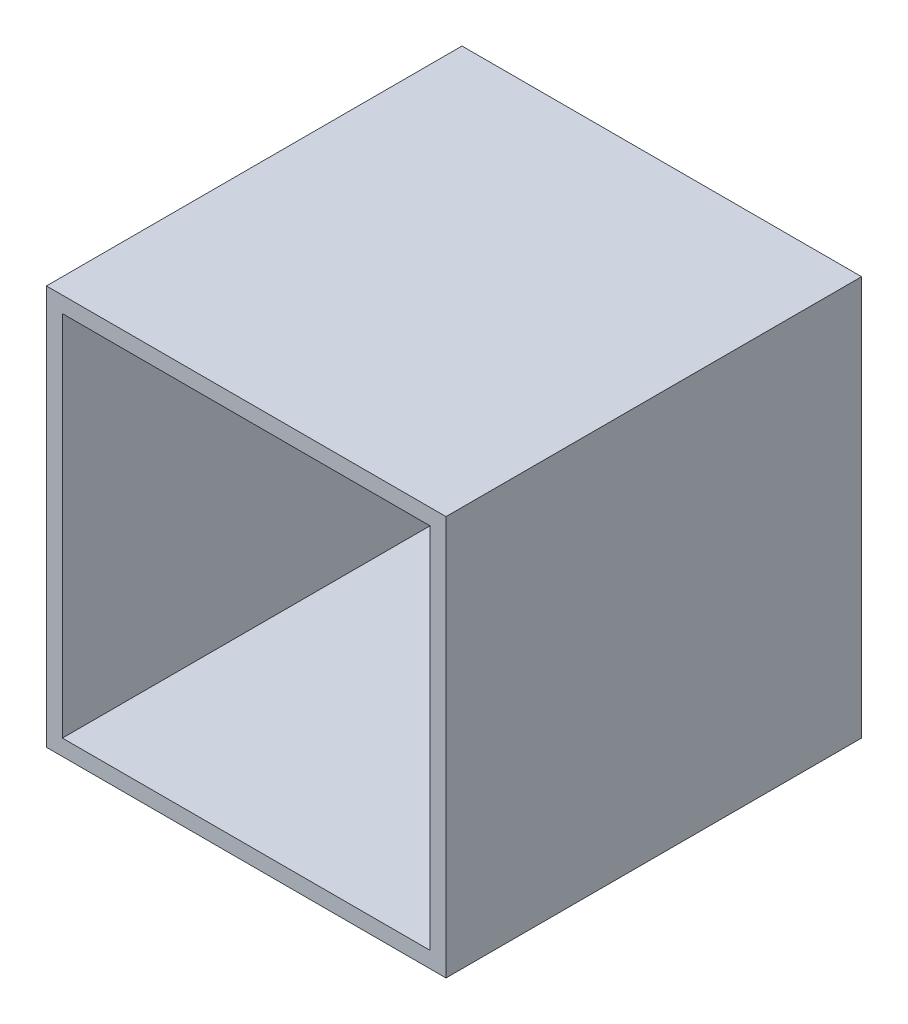
from build123d import *

# Parameters (mm, degrees)
CROQUIS1_W              = 50
CROQUIS1_H              = 50
SALIENTE_EXTRUIR1_DEPTH = 52
CROQUIS2_W              = 46
CROQUIS2_H              = 46
CORTAR_EXTRUIR1_DEPTH   = 50


with BuildPart() as part:
    # Croquis1 → Saliente-Extruir1 (new body)
    with BuildSketch(Plane.XY):
        with Locations((-52.892949436, 13.184931507)):
            Rectangle(CROQUIS1_W, CROQUIS1_H)
    extrude(amount=SALIENTE_EXTRUIR1_DEPTH)

    # Croquis2 → Cortar-Extruir1 (cut)
    with BuildSketch(Plane.XY.offset(52)):
        with Locations((-52.892949436, 13.184931507)):
            Rectangle(CROQUIS2_W, CROQUIS2_H)
    extrude(amount=-CORTAR_EXTRUIR1_DEPTH, mode=Mode.SUBTRACT)


solid = part.part
